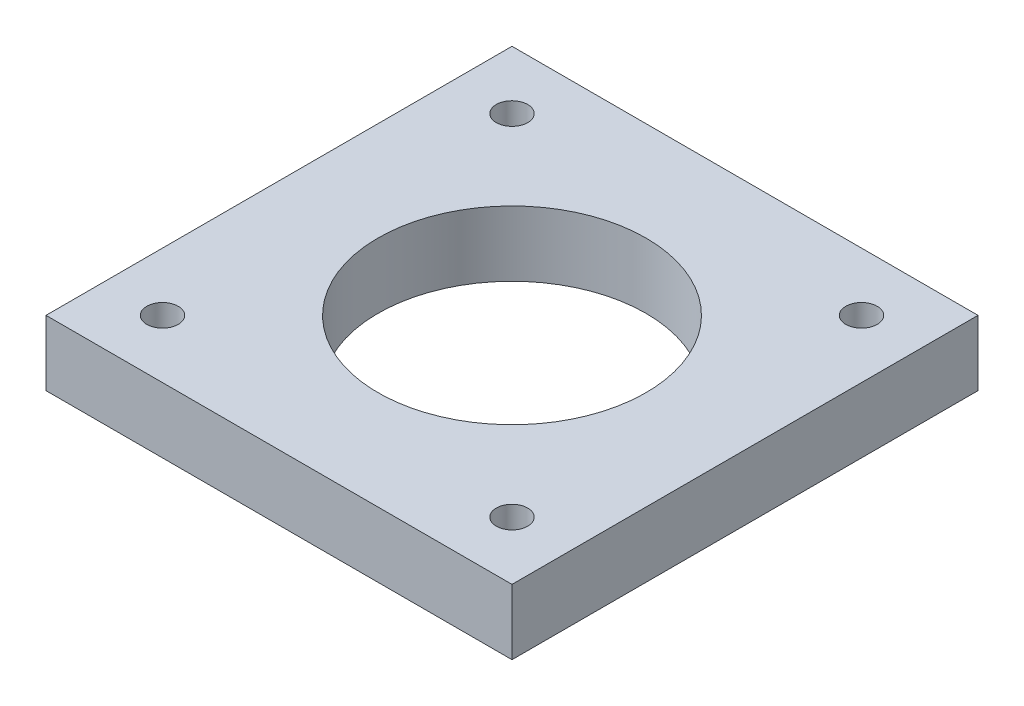
from build123d import *

# Parameters (mm, degrees)
SKETCH1_W           = 40
SKETCH1_H           = 40
BOSS_EXTRUDE1_DEPTH = 5.6
SKETCH2_R           = 11
CUT_EXTRUDE1_DEPTH  = 6.6
SKETCH3_R           = 11.5
CUT_EXTRUDE2_DEPTH  = 7.5
SKETCH5_R           = 1.35
CUT_EXTRUDE4_DEPTH  = 6.6


with BuildPart() as part:
    # Sketch1 → Boss-Extrude1 (new body)
    with BuildSketch(Plane(origin=(0, 0, 0), x_dir=(1, 0, 0), z_dir=(0, 1, 0))):
        Rectangle(SKETCH1_W, SKETCH1_H)
    extrude(amount=BOSS_EXTRUDE1_DEPTH)

    # Sketch2 → Cut-Extrude1 (cut, through all)
    with BuildSketch(Plane(origin=(0, 5.6, 0), x_dir=(1, 0, 0), z_dir=(0, 1, 0))):
        Circle(SKETCH2_R)
    extrude(amount=-CUT_EXTRUDE1_DEPTH, mode=Mode.SUBTRACT)

    # Sketch3 → Cut-Extrude2 (cut)
    with BuildSketch(Plane(origin=(0, 0, 0), x_dir=(-1, 0, 0), z_dir=(0, -1, 0))):
        Circle(SKETCH3_R)
    extrude(amount=-CUT_EXTRUDE2_DEPTH, mode=Mode.SUBTRACT)

    # Sketch5 → Cut-Extrude4 (cut, through all)
    with BuildSketch(Plane(origin=(0, 5.6, 0), x_dir=(1, 0, 0), z_dir=(0, 1, 0))):
        with Locations((-15, 15)):
            Circle(SKETCH5_R)
        with Locations((15, 15)):
            Circle(SKETCH5_R)
        with Locations((15, -15)):
            Circle(SKETCH5_R)
        with Locations((-15, -15)):
            Circle(SKETCH5_R)
    extrude(amount=-CUT_EXTRUDE4_DEPTH, mode=Mode.SUBTRACT)


solid = part.part
